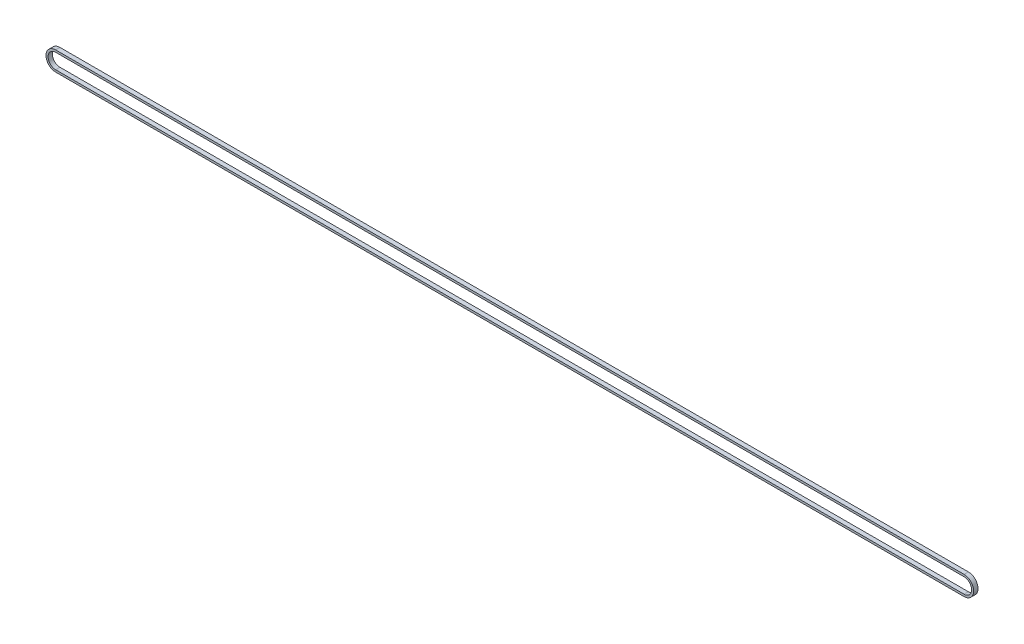
from build123d import *

# Parameters (mm, degrees)
EXTRUDE_THIN1_DEPTH = 2.5


with BuildPart() as part:
    # Sketch1 → Extrude-Thin1 (new body, symmetric)
    with BuildSketch(Plane.XY):
        with BuildLine():
            Line((1051.8, -11.15), (0, -11.15))
            ThreePointArc((0, -11.15), (-11.15, 0), (0, 11.15))
            Line((0, 11.15), (1051.8, 11.15))
            ThreePointArc((1051.8, 11.15), (1062.95, 0), (1051.8, -11.15))
        make_face()
        with BuildLine():
            Line((1051.8, -8.75), (0, -8.75))
            ThreePointArc((0, -8.75), (-8.75, 0), (0, 8.75))
            Line((0, 8.75), (1051.8, 8.75))
            ThreePointArc((1051.8, 8.75), (1060.55, 0), (1051.8, -8.75))
        make_face(mode=Mode.SUBTRACT)
    extrude(amount=EXTRUDE_THIN1_DEPTH, both=True)


solid = part.part
